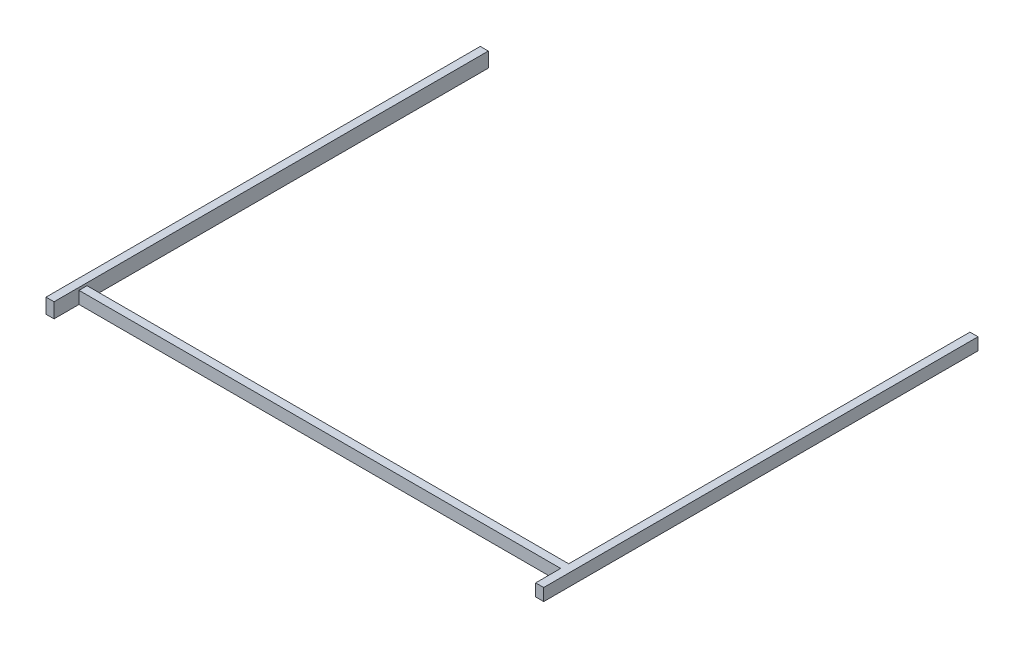
from build123d import *

# Parameters (mm, degrees)
SKETCH1_W        = 100
SKETCH1_H        = 184.8
EXTRUDE1_DEPTH   = 5409.9984
SKETCH1_H_2      = 152.4
EXTRUDE1_2_DEPTH = 5409.9984
SKETCH2_W        = 100
SKETCH2_H        = 152.4
EXTRUDE2_DEPTH   = 6000


with BuildPart() as part:
    # Sketch1 → Extrude1 (new body)
    with BuildSketch(Plane.XY):
        with Locations((-140399.761744046, -60)):
            Rectangle(SKETCH1_W, SKETCH1_H)
    extrude(amount=EXTRUDE1_DEPTH)



with BuildPart() as body_2:
    # Sketch1 → Extrude1 2 (new body)
    with BuildSketch(Plane.XY):
        with Locations((-134299.761744046, -76.2)):
            Rectangle(SKETCH1_W, SKETCH1_H_2)
    extrude(amount=EXTRUDE1_2_DEPTH)


with BuildPart() as part_1:
    add(part.part)

    add(body_2.part)  # Extrude2 merges body 2
    # Sketch2 → Extrude2 (add)
    with BuildSketch(Plane.ZY.offset(134349.761744046)):
        with Locations((5048.721352532, -76.2)):
            Rectangle(SKETCH2_W, SKETCH2_H)
    extrude(amount=EXTRUDE2_DEPTH)


solid = part_1.part
